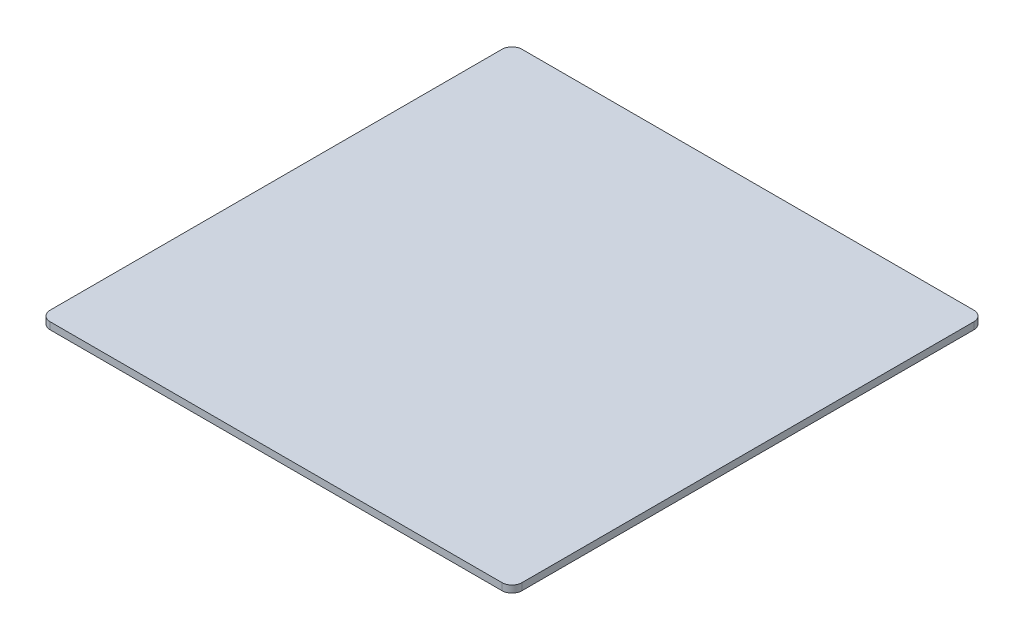
from build123d import *

# Parameters (mm, degrees)
SKETCH1_W            = 235
SKETCH1_H            = 235
BOSS_EXTRUDE1_DEPTH  = 3.5
FILLET1_R            = 5
SKETCH2_R            = 2
CUT_EXTRUDE1_DEPTH   = 1
LPATTERN1_COUNT      = 2
LPATTERN1_PITCH      = 170
LPATTERN1_COUNT_DIR2 = 2
LPATTERN1_PITCH_DIR2 = 170


with BuildPart() as part:
    # Sketch1 → Boss-Extrude1 (new body)
    with BuildSketch(Plane(origin=(0, 0, 0), x_dir=(1, 0, 0), z_dir=(0, 1, 0))):
        Rectangle(SKETCH1_W, SKETCH1_H)
    extrude(amount=BOSS_EXTRUDE1_DEPTH)

    # Fillet1
    fillet1_edges = [part.edges().sort_by_distance(p)[0] for p in [
        (-117.5, 1.75, -117.5),
        (117.5, 1.75, -117.5),
        (117.5, 1.75, 117.5),
        (-117.5, 1.75, 117.5),
    ]]
    fillet(fillet1_edges, radius=FILLET1_R)

    # Sketch2 → Cut-Extrude1 (cut)
    with BuildSketch(Plane.XZ):
        with Locations((-85, -85)):
            Circle(SKETCH2_R)
    cut_extrude1 = extrude(amount=-CUT_EXTRUDE1_DEPTH, mode=Mode.SUBTRACT)

    # LPattern1: Cut-Extrude1 2 × 2
    with Locations(*[(j * LPATTERN1_PITCH_DIR2, 0, i * LPATTERN1_PITCH) for i in range(LPATTERN1_COUNT) for j in range(LPATTERN1_COUNT_DIR2) if (i, j) != (0, 0)]):
        add(cut_extrude1, mode=Mode.SUBTRACT)


solid = part.part
